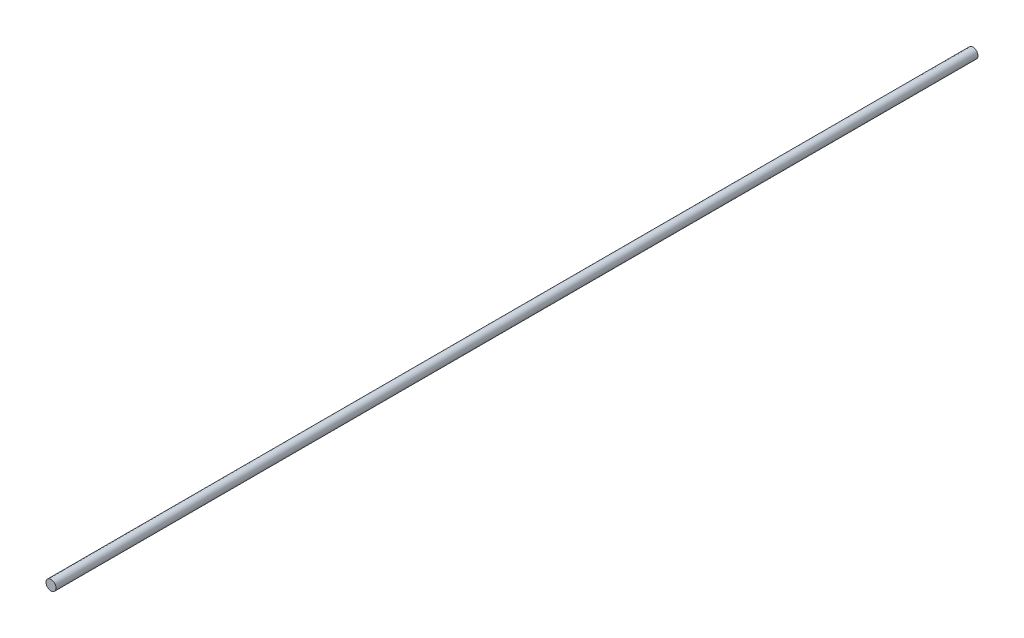
from build123d import *

# Parameters (mm, degrees)
SKETCH1_R           = 27.5
BOSS_EXTRUDE1_DEPTH = 5070
SCALE1_SCALE        = 0.1


with BuildPart() as part:
    # Sketch1 → Boss-Extrude1 (new body)
    with BuildSketch(Plane.XY):
        Circle(SKETCH1_R)
    extrude(amount=BOSS_EXTRUDE1_DEPTH)


with BuildPart() as part_1:
    # Scale1: scaled about (0, 0, 2535)
    add(part.part.scale(SCALE1_SCALE).moved(Location((0, 0, 2281.5))))


solid = part_1.part
